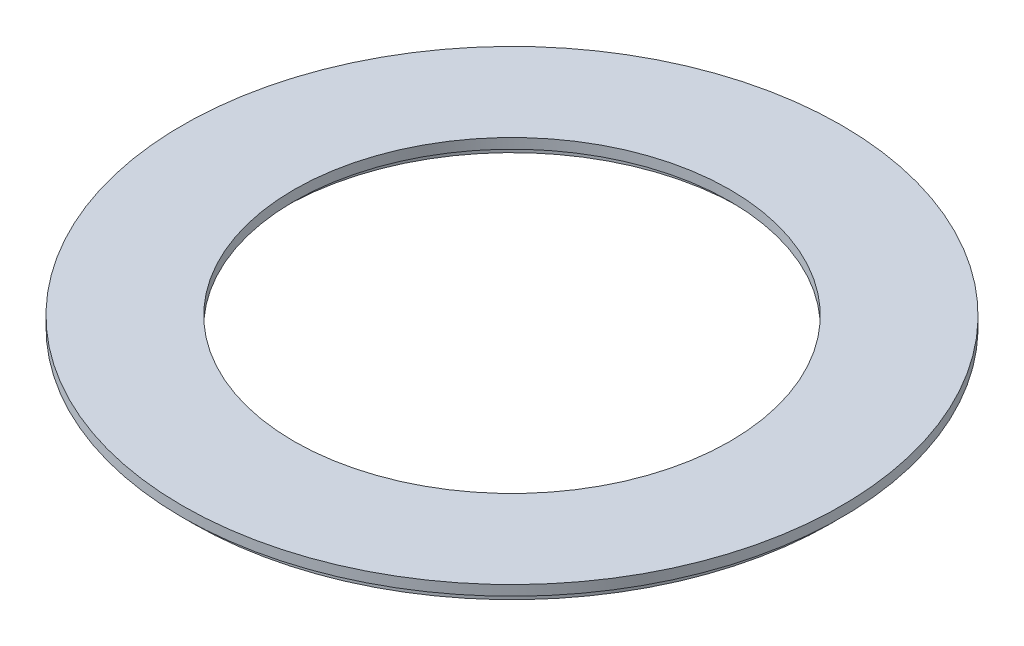
from build123d import *

# Parameters (mm, degrees)
SKETCH1_R           = 16.25
SKETCH1_R_2         = 10.75
BOSS_EXTRUDE1_DEPTH = 0.5
SKETCH2_R           = 15.75
SKETCH2_R_2         = 11.25
BOSS_EXTRUDE2_DEPTH = 0.5


with BuildPart() as part:
    # Sketch1 → Boss-Extrude1 (new body)
    with BuildSketch(Plane(origin=(0, 0, 0), x_dir=(1, 0, 0), z_dir=(0, 1, 0))):
        Circle(SKETCH1_R)
        Circle(SKETCH1_R_2, mode=Mode.SUBTRACT)
    extrude(amount=BOSS_EXTRUDE1_DEPTH)

    # Sketch2 → Boss-Extrude2 (add)
    with BuildSketch(Plane.XZ):
        Circle(SKETCH2_R)
        Circle(SKETCH2_R_2, mode=Mode.SUBTRACT)
    extrude(amount=BOSS_EXTRUDE2_DEPTH)


solid = part.part
